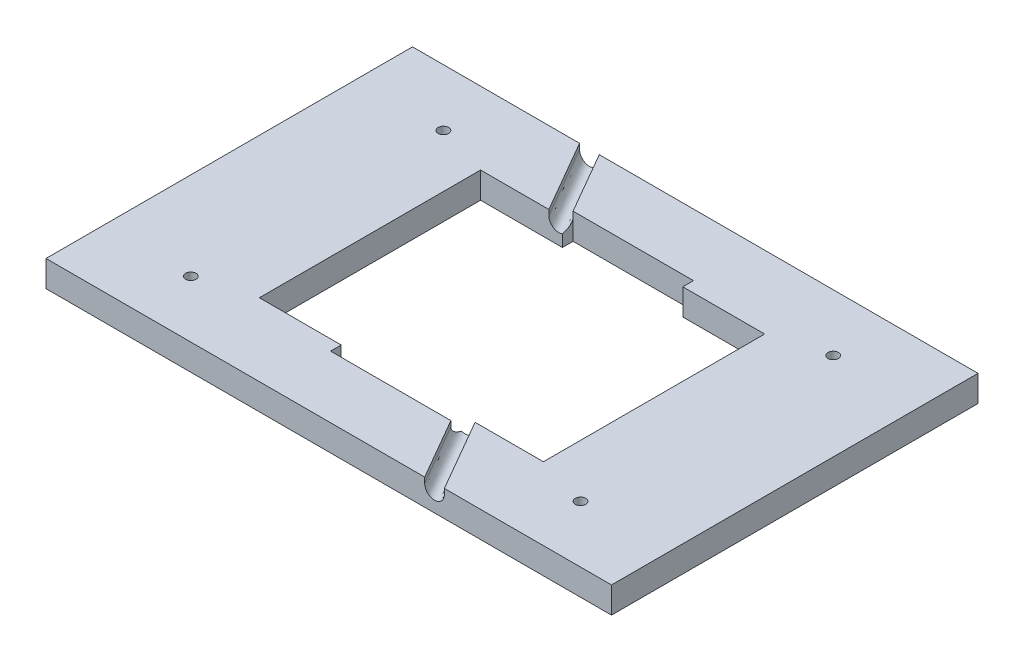
from build123d import *

# Parameters (mm, degrees)
SCHIZZO1_W                   = 108
SCHIZZO1_H                   = 70
SCHIZZO1_R                   = 8.125
ESTRUSIONE_ESTRUSIONE2_DEPTH = 5
TAGLIO_ESTRUSIONE4_DEPTH     = 1
SCHIZZO8_R                   = 1.88
TAGLIO_ESTRUSIONE5_DEPTH     = 95
SCHIZZO9_W                   = 54
SCHIZZO9_H                   = 42
TAGLIO_ESTRUSIONE6_DEPTH     = 10
SCHIZZO10_W                  = 22.988764944
SCHIZZO10_H                  = 46.310438252
TAGLIO_ESTRUSIONE7_DEPTH     = 10
SCHIZZO11_W                  = 54.25
SCHIZZO11_H                  = 42.25
TAGLIO_ESTRUSIONE8_DEPTH     = 10
SCHIZZO14_R                  = 8.125
ESTRUSIONE_ESTRUSIONE3_DEPTH = 2
SCHIZZO15_R                  = 8.125
ESTRUSIONE_ESTRUSIONE4_DEPTH = 2
TAGLIO_ESTRUSIONE10_DEPTH    = 3
SCHIZZO17_R                  = 1
TAGLIO_ESTRUSIONE11_DEPTH    = 3


with BuildPart() as part:
    # Schizzo1 → Estrusione-Estrusione2 (new body)
    with BuildSketch(Plane(origin=(0, 0, 0), x_dir=(1, 0, 0), z_dir=(0, 1, 0))):
        Rectangle(SCHIZZO1_W, SCHIZZO1_H)
        with Locations((-37.216940269, -24.122090915)):
            Circle(SCHIZZO1_R, mode=Mode.SUBTRACT)
        with Locations((-37.216940269, 24.122090915)):
            Circle(SCHIZZO1_R, mode=Mode.SUBTRACT)
        with Locations((37.216940269, 24.122090915)):
            Circle(SCHIZZO1_R, mode=Mode.SUBTRACT)
        with Locations((37.216940269, -24.122090915)):
            Circle(SCHIZZO1_R, mode=Mode.SUBTRACT)
        with BuildLine():
            Line((16.970562748, 21), (-16.970562748, 21))
            ThreePointArc((-16.970562748, 21), (-27, 0), (-16.970562748, -21))
            Line((-16.970562748, -21), (16.970562748, -21))
            ThreePointArc((16.970562748, -21), (27, 0), (16.970562748, 21))
        make_face(mode=Mode.SUBTRACT)
    extrude(amount=ESTRUSIONE_ESTRUSIONE2_DEPTH)

    # Schizzo5 → Taglio-Estrusione4 (cut)
    with BuildSketch(Plane(origin=(0, 5, 0), x_dir=(1, 0, 0), z_dir=(0, 1, 0))):
        Polygon((-22.093333333, 35), (18.323333333, -35), (22.083333333, -35), (-18.333333333, 35), align=None)
    extrude(amount=-TAGLIO_ESTRUSIONE4_DEPTH, mode=Mode.SUBTRACT)

    # Schizzo8 → Taglio-Estrusione5 (cut, along a direction that is not the sketch's normal)
    with BuildSketch(Plane.XY.offset(35)):
        with Locations((20.203333333, 4)):
            Circle(SCHIZZO8_R)
    extrude(amount=-TAGLIO_ESTRUSIONE5_DEPTH, dir=(0.500019929, 0, 0.866013898), mode=Mode.SUBTRACT)

    # Schizzo9 → Taglio-Estrusione6 (cut)
    with BuildSketch(Plane(origin=(0, 5, 0), x_dir=(1, 0, 0), z_dir=(0, 1, 0))):
        Rectangle(SCHIZZO9_W, SCHIZZO9_H)
    extrude(amount=-TAGLIO_ESTRUSIONE6_DEPTH, mode=Mode.SUBTRACT)

    # Schizzo10 → Taglio-Estrusione7 (cut)
    with BuildSketch(Plane(origin=(0, 5, 0), x_dir=(1, 0, 0), z_dir=(0, 1, 0))):
        Rectangle(SCHIZZO10_W, SCHIZZO10_H)
    extrude(amount=-TAGLIO_ESTRUSIONE7_DEPTH, mode=Mode.SUBTRACT)

    # Schizzo11 → Taglio-Estrusione8 (cut)
    with BuildSketch(Plane(origin=(0, 5, 0), x_dir=(1, 0, 0), z_dir=(0, 1, 0))):
        Rectangle(SCHIZZO11_W, SCHIZZO11_H)
    extrude(amount=-TAGLIO_ESTRUSIONE8_DEPTH, mode=Mode.SUBTRACT)

    # Schizzo14 → Estrusione-Estrusione3 (add)
    with BuildSketch(Plane(origin=(0, 5, 0), x_dir=(1, 0, 0), z_dir=(0, 1, 0))):
        with Locations((37.216940269, 24.122090915)):
            Circle(SCHIZZO14_R)
        with Locations((37.216940269, -24.122090915)):
            Circle(SCHIZZO14_R)
    extrude(amount=-ESTRUSIONE_ESTRUSIONE3_DEPTH)

    # Schizzo15 → Estrusione-Estrusione4 (add)
    with BuildSketch(Plane(origin=(0, 5, 0), x_dir=(1, 0, 0), z_dir=(0, 1, 0))):
        with Locations((-37.216940269, 24.122090915)):
            Circle(SCHIZZO15_R)
        with Locations((-37.216940269, -24.122090915)):
            Circle(SCHIZZO15_R)
    extrude(amount=-ESTRUSIONE_ESTRUSIONE4_DEPTH)

    # Schizzo16 → Taglio-Estrusione10 (cut)
    with BuildSketch(Plane.XZ):
        Polygon((-40.023183309, 16.497090915), (-34.410697229, 16.497090915), (-37.216940269, 14.997090915), align=None)
        Polygon((-40.023183309, -16.622090915), (-34.410697229, -16.622090915), (-37.216940269, -15.122090915), align=None)
        Polygon((34.410697229, 16.497090915), (40.023183309, 16.497090915), (37.216940269, 14.997090915), align=None)
        Polygon((34.091940269, -16.622090915), (37.216940269, -15.122090915), (40.341940269, -16.622090915), align=None)
    extrude(amount=-TAGLIO_ESTRUSIONE10_DEPTH, mode=Mode.SUBTRACT)

    # Schizzo17 → Taglio-Estrusione11 (cut)
    with BuildSketch(Plane.XZ.offset(-3)):
        with Locations((-37.216940269, 24.122090915)):
            Circle(SCHIZZO17_R)
        with Locations((37.216940269, 24.122090915)):
            Circle(SCHIZZO17_R)
        with Locations((37.216940269, -24.122090915)):
            Circle(SCHIZZO17_R)
        with Locations((-37.216940269, -24.122090915)):
            Circle(SCHIZZO17_R)
    extrude(amount=-TAGLIO_ESTRUSIONE11_DEPTH, mode=Mode.SUBTRACT)


solid = part.part
